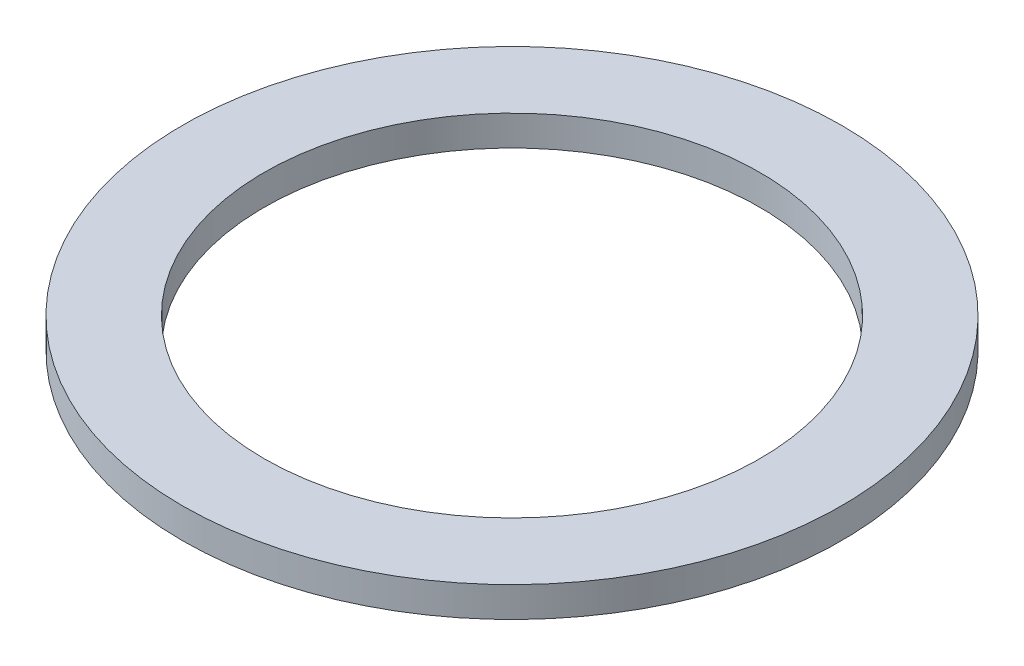
from build123d import *

# Parameters (mm, degrees)
SKETCH1_R           = 5.45
SKETCH1_R_2         = 4.1
BOSS_EXTRUDE1_DEPTH = 0.5


with BuildPart() as part:
    # Sketch1 → Boss-Extrude1 (new body)
    with BuildSketch(Plane(origin=(0, 0, 0), x_dir=(1, 0, 0), z_dir=(0, 1, 0))):
        Circle(SKETCH1_R)
        Circle(SKETCH1_R_2, mode=Mode.SUBTRACT)
    extrude(amount=BOSS_EXTRUDE1_DEPTH)


solid = part.part
